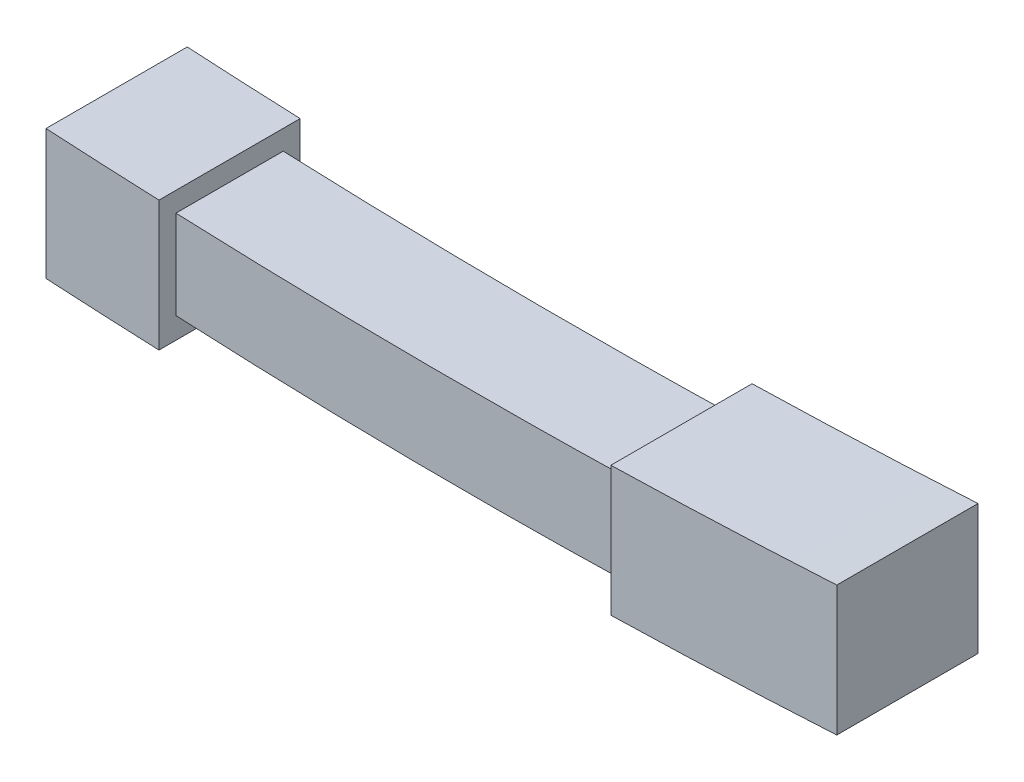
from build123d import *

# Parameters (mm, degrees)
SKETCH1_W           = 140
SKETCH1_H           = 25
BOSS_EXTRUDE1_DEPTH = 25
CUT_EXTRUDE1_DEPTH  = 25
CUT_EXTRUDE13_DEPTH = 3
SKETCH9_W           = 80
SKETCH9_H           = 18.70062617
CUT_EXTRUDE14_DEPTH = 3


with BuildPart() as part:
    # Sketch1 → Boss-Extrude1 (new body)
    with BuildSketch(Plane(origin=(0, 0, 0), x_dir=(1, 0, 0), z_dir=(0, 1, 0))):
        Rectangle(SKETCH1_W, SKETCH1_H)
    extrude(amount=BOSS_EXTRUDE1_DEPTH)

    # Sketch5 → Cut-Extrude1 (cut)
    with BuildSketch(Plane.XY.offset(12.5)):
        with BuildLine():
            add(Edge.make_bspline(
                [(0, 23), (15, 23), (30, 23.367346939)],
                knots=[0.5, 0.5, 0.5, 0.714285714, 0.714285714, 0.714285714], degree=2))
            add(Edge.make_bspline(
                [(30, 23.367346939), (50, 23.857142857), (70, 25)],
                knots=[0.714285714, 0.714285714, 0.714285714, 1, 1, 1], degree=2))
            Line((70, 25), (30, 25))
            Line((30, 25), (0, 25))
            Line((0, 25), (0, 23))
        make_face()
        with BuildLine():
            add(Edge.make_bspline(
                [(-50, 24.020408163), (-25, 23), (0, 23)],
                knots=[0.142857143, 0.142857143, 0.142857143, 0.5, 0.5, 0.5], degree=2))
            Line((0, 23), (0, 25))
            Line((0, 25), (-50, 25))
            Line((-50, 25), (-70, 25))
            add(Edge.make_bspline(
                [(-70, 25), (-60, 24.428571429), (-50, 24.020408163)],
                knots=[0, 0, 0, 0.142857143, 0.142857143, 0.142857143], degree=2))
        make_face()
        with BuildLine():
            Line((30, 19.867346939), (30, 23.367346939))
            add(Edge.make_bspline(
                [(0, 23), (15, 23), (30, 23.367346939)],
                knots=[0.5, 0.5, 0.5, 0.714285714, 0.714285714, 0.714285714], degree=2))
            Line((0, 23), (0, 19.5))
            add(Edge.make_bspline(
                [(0, 19.5), (14.999250637, 19.500030588), (30, 19.867346939)],
                knots=[0.625031228, 0.625031228, 0.625031228, 1, 1, 1], degree=2))
        make_face()
        with BuildLine():
            Line((0, 19.5), (0, 23))
            add(Edge.make_bspline(
                [(-50, 24.020408163), (-25, 23), (0, 23)],
                knots=[0.142857143, 0.142857143, 0.142857143, 0.5, 0.5, 0.5], degree=2))
            Line((-50, 24.020408163), (-50, 21.5))
            Line((-50, 21.5), (-50, 20.520408163))
            add(Edge.make_bspline(
                [(-50, 20.520408163), (-25.002082119, 19.499949013), (0, 19.5)],
                knots=[0, 0, 0, 0.625031228, 0.625031228, 0.625031228], degree=2))
        make_face()
        with BuildLine():
            Line((0, 0), (0, 3.5))
            add(Edge.make_bspline(
                [(-50, 4.813033374), (-25.004215516, 3.554754755), (0, 3.5)],
                knots=[0, 0, 0, 0.625063216, 0.625063216, 0.625063216], degree=2))
            Line((-50, 4.813033374), (-50, 1.020408163))
            add(Edge.make_bspline(
                [(-50, 1.020408163), (-25, 0), (0, 0)],
                knots=[0.142857143, 0.142857143, 0.142857143, 0.5, 0.5, 0.5], degree=2))
        make_face()
        with BuildLine():
            Line((30, 0.367346939), (30, 3.867346939))
            add(Edge.make_bspline(
                [(0, 3.5), (14.998483233, 3.467156007), (30, 3.867346939)],
                knots=[0.625063216, 0.625063216, 0.625063216, 1, 1, 1], degree=2))
            Line((0, 3.5), (0, 0))
            add(Edge.make_bspline(
                [(0, 0), (15, 0), (30, 0.367346939)],
                knots=[0.5, 0.5, 0.5, 0.714285714, 0.714285714, 0.714285714], degree=2))
        make_face()
        with BuildLine():
            Line((70, 0), (70, 2))
            add(Edge.make_bspline(
                [(30, 0.367346939), (50, 0.857142857), (70, 2)],
                knots=[0.714285714, 0.714285714, 0.714285714, 1, 1, 1], degree=2))
            add(Edge.make_bspline(
                [(0, 0), (15, 0), (30, 0.367346939)],
                knots=[0.5, 0.5, 0.5, 0.714285714, 0.714285714, 0.714285714], degree=2))
            Line((0, 0), (70, 0))
        make_face()
        with BuildLine():
            Line((-70, 0), (0, 0))
            add(Edge.make_bspline(
                [(-50, 1.020408163), (-25, 0), (0, 0)],
                knots=[0.142857143, 0.142857143, 0.142857143, 0.5, 0.5, 0.5], degree=2))
            add(Edge.make_bspline(
                [(-70, 2), (-60, 1.428571429), (-50, 1.020408163)],
                knots=[0, 0, 0, 0.142857143, 0.142857143, 0.142857143], degree=2))
            Line((-70, 2), (-70, 0))
        make_face()
    extrude(amount=-CUT_EXTRUDE1_DEPTH, mode=Mode.SUBTRACT)

    # Sketch6 → Cut-Extrude13 (cut)
    with BuildSketch(Plane.XY.offset(12.5)):
        with BuildLine():
            Line((30, 1.485887188), (30, 3.867346939))
            add(Edge.make_bspline(
                [(-50, 4.813033374), (-10.010789538, 2.799991192), (30, 3.867346939)],
                knots=[0, 0, 0, 1, 1, 1], degree=2))
            Line((-50, 4.813033374), (-50, 1.485887188))
            Line((-50, 1.485887188), (30, 1.485887188))
        make_face()
        with BuildLine():
            Line((-50, 20.520408163), (-50, 4.813033374))
            add(Edge.make_bspline(
                [(-50, 4.813033374), (-10.010789538, 2.799991192), (30, 3.867346939)],
                knots=[0, 0, 0, 1, 1, 1], degree=2))
            Line((30, 3.867346939), (30, 19.867346939))
            add(Edge.make_bspline(
                [(30, 19.867346939), (-10.005329691, 18.887755097), (-50, 20.520408163)],
                knots=[0, 0, 0, 1, 1, 1], degree=2))
        make_face()
        Polygon((-50, 20.520408163), (30, 19.867346939), (30, 20.995155466), (30, 21.46990277), (-50, 21.46990277), align=None)
        with BuildLine():
            Line((-50, 20.520408163), (30, 19.867346939))
            add(Edge.make_bspline(
                [(30, 19.867346939), (-10.005329691, 18.887755097), (-50, 20.520408163)],
                knots=[0, 0, 0, 1, 1, 1], degree=2))
        make_face()
    extrude(amount=-CUT_EXTRUDE13_DEPTH, mode=Mode.SUBTRACT)

    # Sketch9 → Cut-Extrude14 (cut)
    with BuildSketch(Plane(origin=(0, 0, -12.5), x_dir=(-1, 0, 0), z_dir=(0, 0, -1))):
        with Locations((10, 12.267033854)):
            Rectangle(SKETCH9_W, SKETCH9_H)
    extrude(amount=-CUT_EXTRUDE14_DEPTH, mode=Mode.SUBTRACT)


solid = part.part
